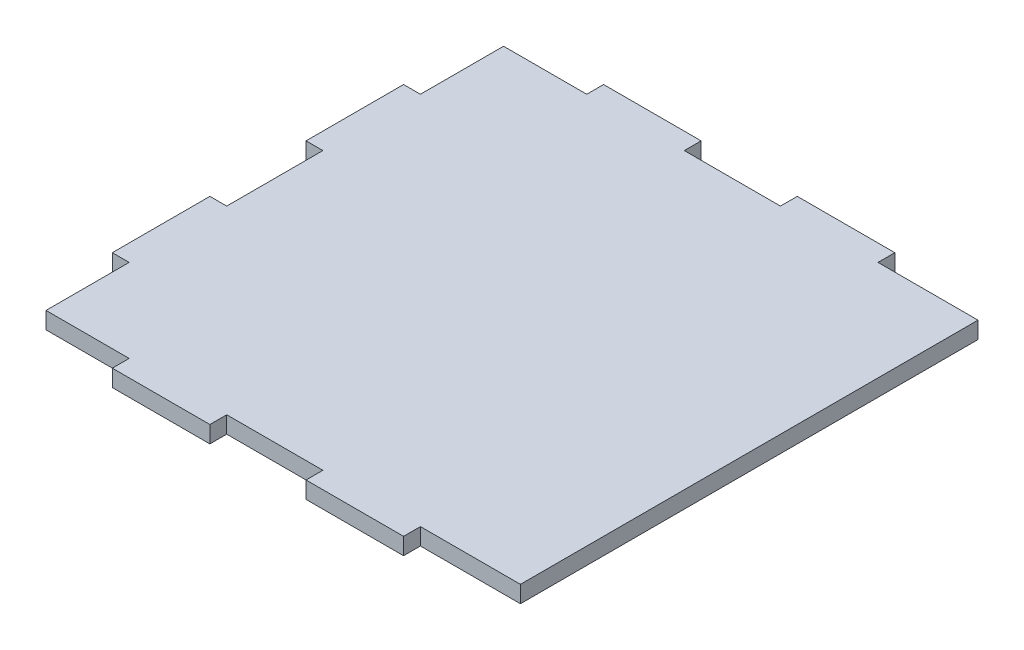
from build123d import *

# Parameters (mm, degrees)
BOSS_EXTRUDE1_DEPTH = 12


with BuildPart() as part:
    # Sketch1 → Boss-Extrude1 (new body)
    with BuildSketch(Plane(origin=(0, 0, 0), x_dir=(1, 0, 0), z_dir=(0, 1, 0))):
        Polygon((12, 12), (12, 71.25), (0, 71.25), (0, 140.75), (12, 140.75), (12, 209.25), (0, 209.25), (0, 278.75), (12, 278.75), (12, 338), (71.25, 338), (71.25, 350), (140.75, 350), (140.75, 338), (209.25, 338), (209.25, 350), (278.75, 350), (278.75, 338), (350, 338), (350, 12), (278.75, 12), (278.75, 0), (209.25, 0), (209.25, 12), (140.75, 12), (140.75, 0), (71.25, 0), (71.25, 12), align=None)
    extrude(amount=BOSS_EXTRUDE1_DEPTH)


solid = part.part
